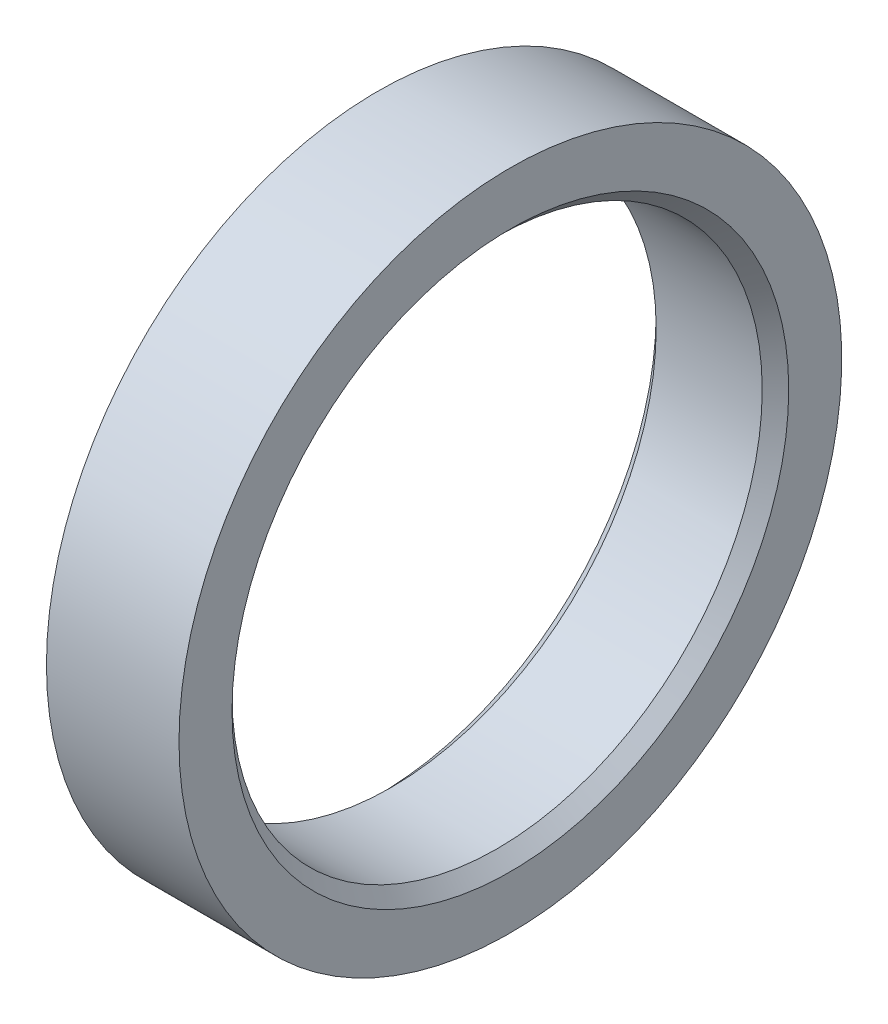
from build123d import *

# Parameters (mm, degrees)
SKICA1_W      = 10
SKICA1_H      = 5
ZKOSEN_1_SIZE = 1


with BuildPart() as part:
    # Skica1 → Rotovat1 (revolve)
    with BuildSketch(Plane.XY):
        with Locations((5, 22.5)):
            Rectangle(SKICA1_W, SKICA1_H)
    revolve(axis=Axis((0, 0, 0), (1, 0, 0)))

    # Zkosení1
    zkosen_1_edges = [part.edges().sort_by_distance(p)[0] for p in [
        (0, -20, 0),
        (10, -20, 0),
    ]]
    chamfer(zkosen_1_edges, length=ZKOSEN_1_SIZE)


solid = part.part
